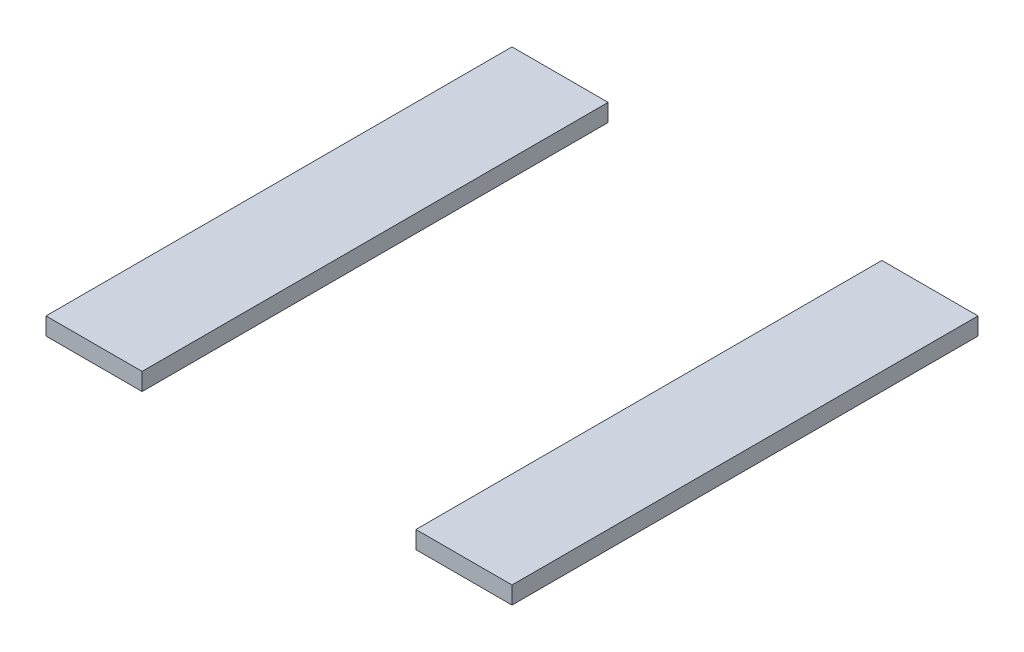
from build123d import *

# Parameters (mm, degrees)
SKETCH1_W             = 16.5
SKETCH1_H             = 80
BOSS_EXTRUDE1_DEPTH   = 3
BOSS_EXTRUDE1_2_DEPTH = 3


with BuildPart() as part:
    # Sketch1 → Boss-Extrude1 (new body)
    with BuildSketch(Plane(origin=(0, 0, 0), x_dir=(1, 0, 0), z_dir=(0, 1, 0))):
        with Locations((-71.75, 40)):
            Rectangle(SKETCH1_W, SKETCH1_H)
    extrude(amount=-BOSS_EXTRUDE1_DEPTH)


with BuildPart() as body_2:
    # Sketch1 → Boss-Extrude1 2 (new body)
    with BuildSketch(Plane(origin=(0, 0, 0), x_dir=(1, 0, 0), z_dir=(0, 1, 0))):
        with Locations((-8.25, 40)):
            Rectangle(SKETCH1_W, SKETCH1_H)
    extrude(amount=-BOSS_EXTRUDE1_2_DEPTH)


solid = Compound([part.part, body_2.part])
